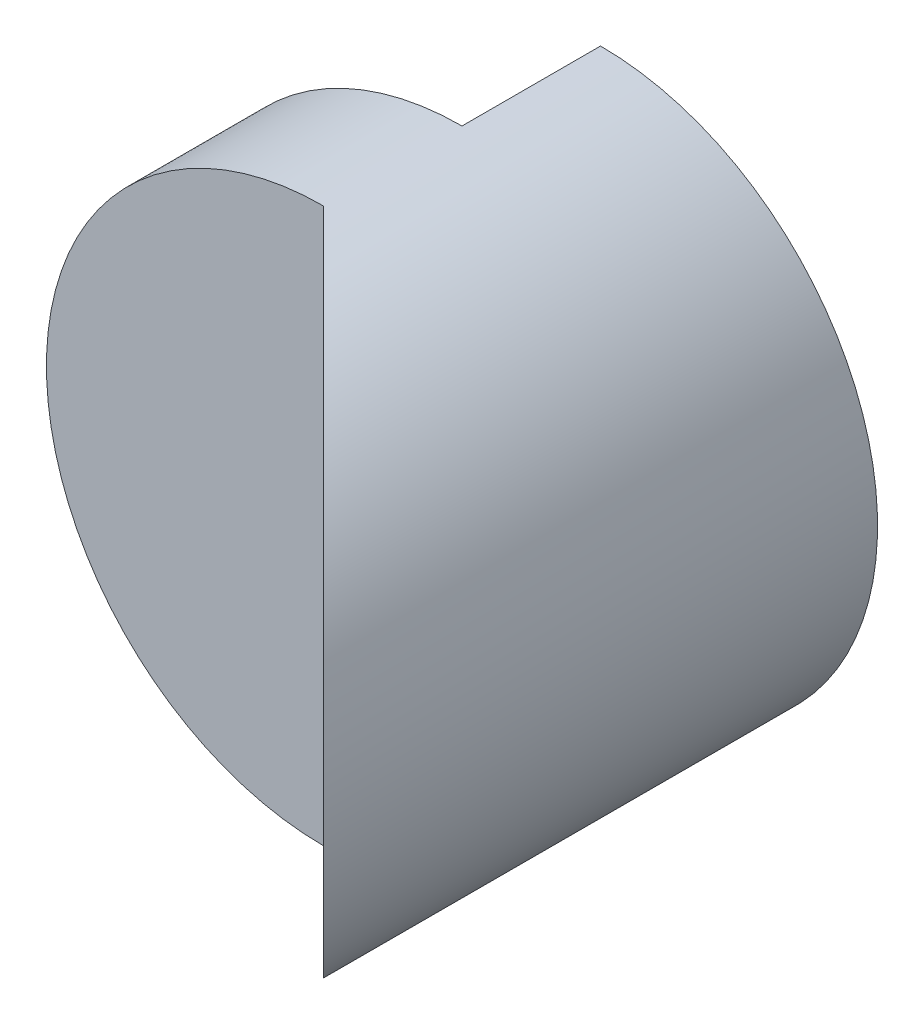
from build123d import *

# Parameters (mm, degrees)
SKETCH1_R               = 20
BOSS_EXTRUDE1_DEPTH     = 40
CUT_EXTRUDE2_DEPTH      = 40
CUT_EXTRUDE2_DEPTH_BACK = 40
SKETCH2_W               = 20
SKETCH2_H               = 10


with BuildPart() as part:
    # Sketch1 → Boss-Extrude1 (new body)
    with BuildSketch(Plane.XY):
        Circle(SKETCH1_R)
    extrude(amount=BOSS_EXTRUDE1_DEPTH)

    # Sketch2 → Cut-Extrude2 (cut, two sides: drawn at the far end of the back side and taken through both)
    with BuildSketch(Plane(origin=(0, 0, 0), x_dir=(1, 0, 0), z_dir=(0, 1, 0)).offset(-CUT_EXTRUDE2_DEPTH_BACK)):
        Polygon((-20, -20), (0, -20), (20, -40), (-20, -40), align=None)
        with Locations((-10, -5)):
            Rectangle(SKETCH2_W, SKETCH2_H)
    extrude(amount=CUT_EXTRUDE2_DEPTH + CUT_EXTRUDE2_DEPTH_BACK, mode=Mode.SUBTRACT)


solid = part.part
